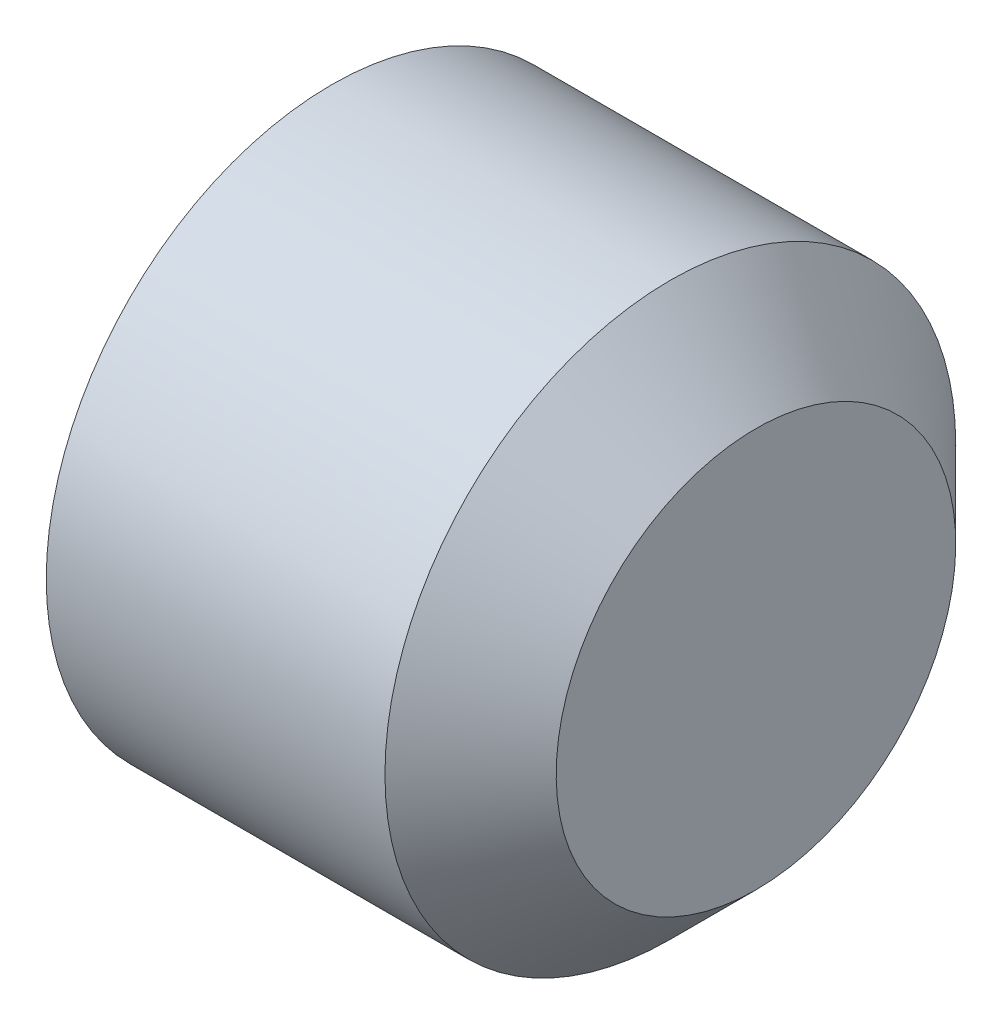
from build123d import *

# Parameters (mm, degrees)
CUT_EXTRUDE1_DEPTH = 2


with BuildPart() as part:
    # Sketch1 → Revolve1 (revolve)
    with BuildSketch(Plane.XY):
        Polygon((4, 0), (4, -1.75), (3.25, -2.5), (0.283190307, -2.5), (0, -2.0095), (0, -1.443375673), (0.833333333, 0), align=None)
    revolve(axis=Axis((0.833333333, 0, 0), (1, 0, 0)))

    # Sketch2 → Cut-Extrude1 (cut)
    with BuildSketch(Plane(origin=(0, 0, 0), x_dir=(0, 0, -1), z_dir=(1, 0, 0))):
        Polygon((-1.443375673, 0), (-0.721687836, -1.25), (0.721687836, -1.25), (1.443375673, 0), (0.721687836, 1.25), (-0.721687836, 1.25), align=None)
    extrude(amount=CUT_EXTRUDE1_DEPTH, mode=Mode.SUBTRACT)


solid = part.part
